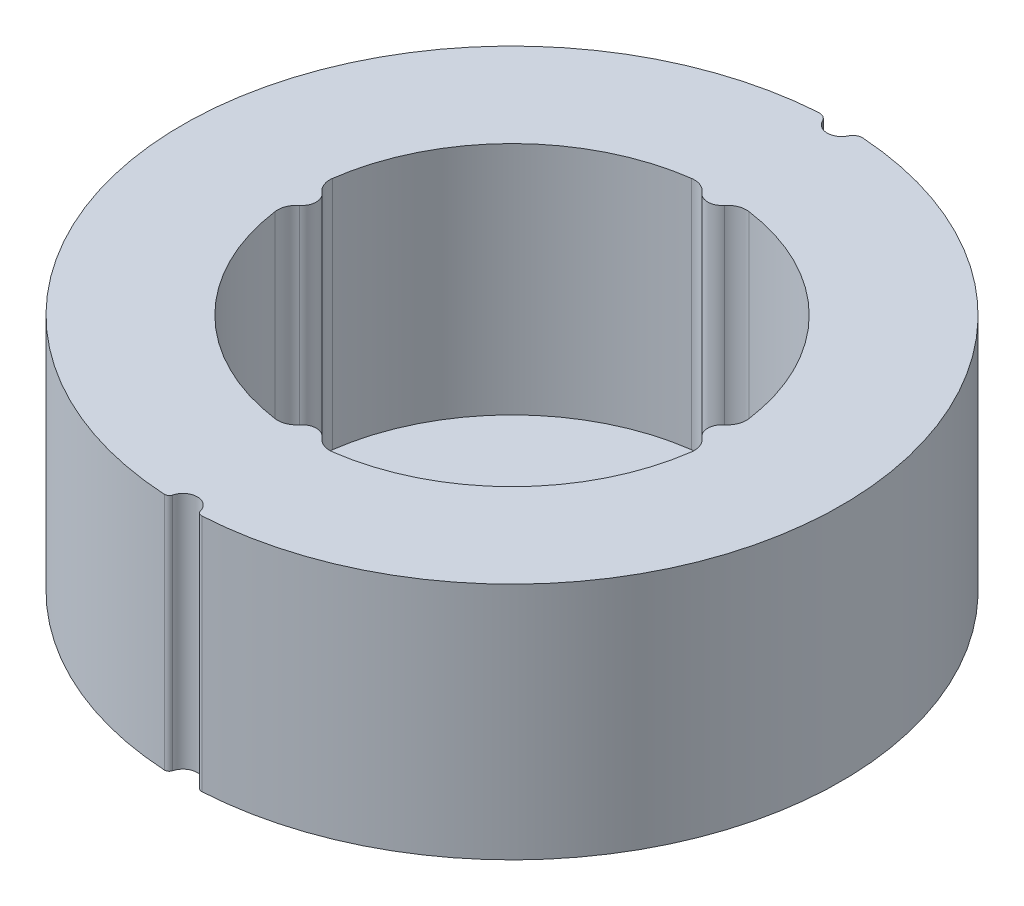
from build123d import *

# Parameters (mm, degrees)
BOSS_EXTRUDE1_DEPTH = 25
CUT_EXTRUDE2_DEPTH  = 55.786493398
BOSS_EXTRUDE2_DEPTH = 0.4


with BuildPart() as part:
    # Sketch1 → Boss-Extrude1 (new body)
    with BuildSketch(Plane(origin=(0, 0, 0), x_dir=(1, 0, 0), z_dir=(0, 1, 0))):
        with BuildLine():
            ThreePointArc((1.451818925, -34.068556857), (1.641248992, -34.346908706), (1.964225605, -34.442038138))
            ThreePointArc((1.964225605, -34.442038138), (26.591847487, -21.978073076), (34.198225299, 4.555174015))
            ThreePointArc((34.198225299, 4.555174015), (23.590291339, 25.176355888), (2.324135821, 34.423627607))
            ThreePointArc((2.324135821, 34.423627607), (1.751838249, 34.289058819), (1.354061739, 33.856153382))
            ThreePointArc((1.354061739, 33.856153382), (0, 33.001534515), (-1.354061739, 33.856153382))
            ThreePointArc((-1.354061739, 33.856153382), (-1.751838249, 34.289058819), (-2.324135821, 34.423627607))
            ThreePointArc((-2.324135821, 34.423627607), (-23.590291339, 25.176355888), (-34.198225299, 4.555174015))
            ThreePointArc((-34.198225299, 4.555174015), (-26.591847487, -21.978073076), (-1.964225605, -34.442038138))
            ThreePointArc((-1.964225605, -34.442038138), (-1.641248992, -34.346908706), (-1.451818925, -34.068556857))
            ThreePointArc((-1.451818925, -34.068556857), (0, -32.945679925), (1.451818925, -34.068556857))
        make_face()
        with BuildLine():
            Line((-2.417, 3.787737139), (0, 3.787737139))
            Line((0, 3.787737139), (2.417, 3.787737139))
            ThreePointArc((2.417, 3.787737139), (0, -4.489512172), (-2.417, 3.787737139))
        make_face(mode=Mode.SUBTRACT)
    extrude(amount=BOSS_EXTRUDE1_DEPTH)

    # Sketch2 → Cut-Extrude2 (cut, through all)
    with BuildSketch(Plane(origin=(0, 0, 0), x_dir=(1, 0, 0), z_dir=(0, 1, 0))):
        with BuildLine():
            ThreePointArc((-21.79375, -3.005405287), (-15.556349186, -15.556349186), (-3.005405287, -21.79375))
            ThreePointArc((-3.005405287, -21.79375), (-1.991620962, -21.670338125), (-1.170937125, -21.0625))
            ThreePointArc((-1.170937125, -21.0625), (0, -20.5), (1.170937125, -21.0625))
            ThreePointArc((1.170937125, -21.0625), (1.991620962, -21.670338125), (3.005405287, -21.79375))
            ThreePointArc((3.005405287, -21.79375), (15.556349186, -15.556349186), (21.79375, -3.005405287))
            ThreePointArc((21.79375, -3.005405287), (21.670338125, -1.991620962), (21.0625, -1.170937125))
            ThreePointArc((21.0625, -1.170937125), (20.5, 0), (21.0625, 1.170937125))
            ThreePointArc((21.0625, 1.170937125), (21.670338125, 1.991620962), (21.79375, 3.005405287))
            ThreePointArc((21.79375, 3.005405287), (15.556349186, 15.556349186), (3.005405287, 21.79375))
            ThreePointArc((3.005405287, 21.79375), (1.991620962, 21.670338125), (1.170937125, 21.0625))
            ThreePointArc((1.170937125, 21.0625), (0, 20.5), (-1.170937125, 21.0625))
            ThreePointArc((-1.170937125, 21.0625), (-1.991620962, 21.670338125), (-3.005405287, 21.79375))
            ThreePointArc((-3.005405287, 21.79375), (-15.556349186, 15.556349186), (-21.79375, 3.005405287))
            ThreePointArc((-21.79375, 3.005405287), (-21.670338125, 1.991620962), (-21.0625, 1.170937125))
            ThreePointArc((-21.0625, 1.170937125), (-20.5, 0), (-21.0625, -1.170937125))
            ThreePointArc((-21.0625, -1.170937125), (-21.670338125, -1.991620962), (-21.79375, -3.005405287))
        make_face()
    extrude(amount=CUT_EXTRUDE2_DEPTH, mode=Mode.SUBTRACT)

    # Sketch2_2 → Boss-Extrude2 (add)
    with BuildSketch(Plane(origin=(0, 0, 0), x_dir=(1, 0, 0), z_dir=(0, 1, 0))):
        with BuildLine():
            ThreePointArc((-21.79375, -3.005405287), (-15.556349186, -15.556349186), (-3.005405287, -21.79375))
            ThreePointArc((-3.005405287, -21.79375), (-1.991620962, -21.670338125), (-1.170937125, -21.0625))
            ThreePointArc((-1.170937125, -21.0625), (0, -20.5), (1.170937125, -21.0625))
            ThreePointArc((1.170937125, -21.0625), (1.991620962, -21.670338125), (3.005405287, -21.79375))
            ThreePointArc((3.005405287, -21.79375), (15.556349186, -15.556349186), (21.79375, -3.005405287))
            ThreePointArc((21.79375, -3.005405287), (21.670338125, -1.991620962), (21.0625, -1.170937125))
            ThreePointArc((21.0625, -1.170937125), (20.5, 0), (21.0625, 1.170937125))
            ThreePointArc((21.0625, 1.170937125), (21.670338125, 1.991620962), (21.79375, 3.005405287))
            ThreePointArc((21.79375, 3.005405287), (15.556349186, 15.556349186), (3.005405287, 21.79375))
            ThreePointArc((3.005405287, 21.79375), (1.991620962, 21.670338125), (1.170937125, 21.0625))
            ThreePointArc((1.170937125, 21.0625), (0, 20.5), (-1.170937125, 21.0625))
            ThreePointArc((-1.170937125, 21.0625), (-1.991620962, 21.670338125), (-3.005405287, 21.79375))
            ThreePointArc((-3.005405287, 21.79375), (-15.556349186, 15.556349186), (-21.79375, 3.005405287))
            ThreePointArc((-21.79375, 3.005405287), (-21.670338125, 1.991620962), (-21.0625, 1.170937125))
            ThreePointArc((-21.0625, 1.170937125), (-20.5, 0), (-21.0625, -1.170937125))
            ThreePointArc((-21.0625, -1.170937125), (-21.670338125, -1.991620962), (-21.79375, -3.005405287))
        make_face()
    extrude(amount=BOSS_EXTRUDE2_DEPTH)


solid = part.part
